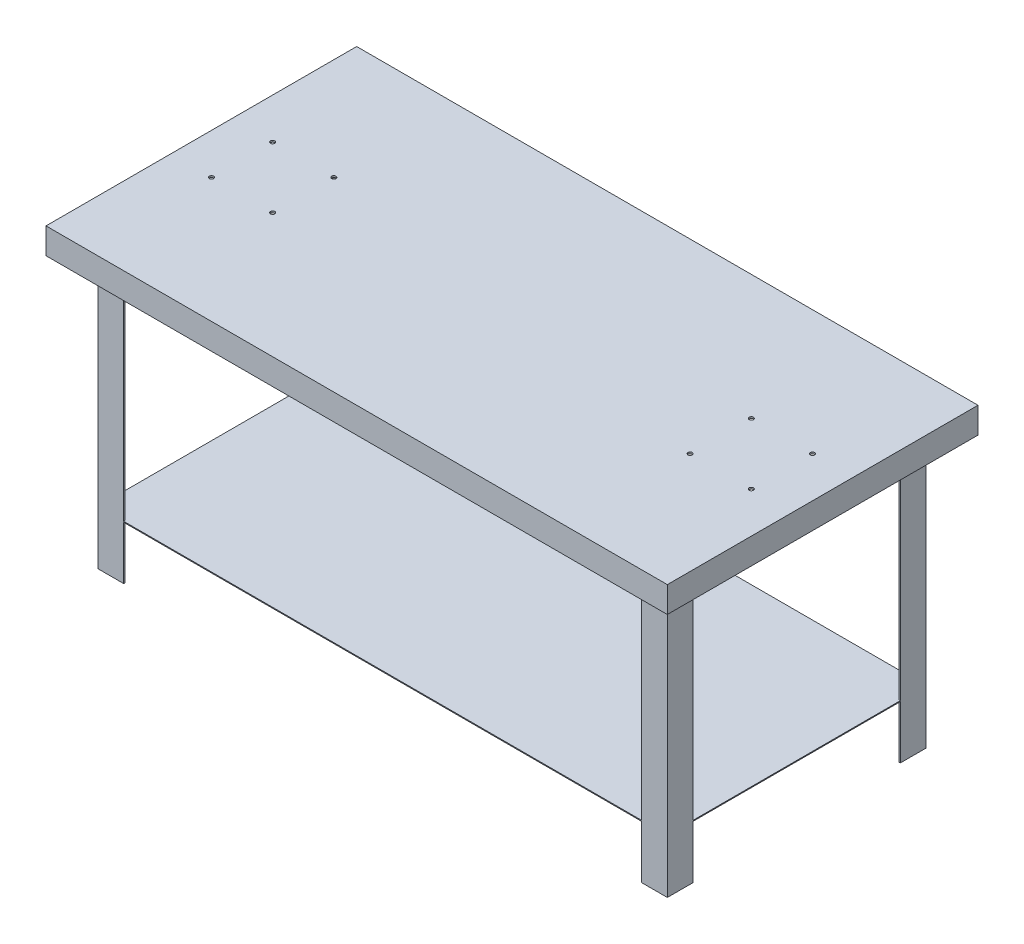
from build123d import *

# Parameters (mm, degrees)
BOSS_EXTRUDE1_DEPTH = 914.4
BOSS_EXTRUDE2_DEPTH = 457.2
BOSS_EXTRUDE3_DEPTH = 868.9975
BOSS_EXTRUDE4_START = 712.7875
SKETCH5_W           = 1676.4
SKETCH5_H           = 762
BOSS_EXTRUDE4_DEPTH = 2.657
SKETCH6_R           = 6.35
CUT_EXTRUDE1_DEPTH  = 10
BOSS_EXTRUDE5_DEPTH = 779


with BuildPart() as part:
    # Sketch1 → Boss-Extrude1 (new body, symmetric)
    with BuildSketch(Plane(origin=(0, 0, 0), x_dir=(0, 0, -1), z_dir=(1, 0, 0))):
        Polygon((-457.2, 0), (457.2, 0), (457.2, -76.2), (381, -76.2), (381, -71.4375), (452.4375, -71.4375), (452.4375, -4.7625), (-452.4375, -4.7625), (-452.4375, -71.4375), (-381, -71.4375), (-381, -76.2), (-457.2, -76.2), align=None)
    extrude(amount=BOSS_EXTRUDE1_DEPTH, both=True)

    # Sketch2 → Boss-Extrude2 (add, symmetric)
    with BuildSketch(Plane.XY):
        Polygon((-914.4, 0), (-914.4, -76.2), (-838.2, -76.2), (-838.2, -71.4375), (-909.6375, -71.4375), (-909.6375, 0), align=None)
        Polygon((909.6375, 0), (914.4, 0), (914.4, -76.2), (838.2, -76.2), (838.2, -71.4375), (909.6375, -71.4375), align=None)
    extrude(amount=BOSS_EXTRUDE2_DEPTH, both=True)

    # Sketch4 → Boss-Extrude3 (add)
    with BuildSketch(Plane.XZ.offset(4.7625)):
        Polygon((-762, 381), (-838.2, 381), (-838.2, 304.8), (-833.646, 304.8), (-833.646, 376.446), (-762, 376.446), align=None)
        Polygon((-833.646, -376.446), (-762, -376.446), (-762, -381), (-838.2, -381), (-838.2, -304.8), (-833.646, -304.8), align=None)
        Polygon((833.646, -304.8), (833.646, -376.446), (762, -376.446), (762, -381), (838.2, -381), (838.2, -304.8), align=None)
        Polygon((833.646, 376.446), (762, 376.446), (762, 381), (838.2, 381), (838.2, 304.8), (833.646, 304.8), align=None)
    extrude(amount=BOSS_EXTRUDE3_DEPTH)

    # Sketch5 → Boss-Extrude4 (add)
    with BuildSketch(Plane.XZ.offset(4.7625).offset(BOSS_EXTRUDE4_START)):
        Rectangle(SKETCH5_W, SKETCH5_H)
    extrude(amount=-BOSS_EXTRUDE4_DEPTH)

    # Sketch6 → Cut-Extrude1 (cut)
    with BuildSketch(Plane(origin=(0, 0, 0), x_dir=(1, 0, 0), z_dir=(0, 1, 0))):
        with Locations((-794.4, 90)):
            Circle(SKETCH6_R)
        with Locations((-614.4, 90)):
            Circle(SKETCH6_R)
        with Locations((-794.4, -90)):
            Circle(SKETCH6_R)
        with Locations((-614.4, -90)):
            Circle(SKETCH6_R)
        with Locations((614.4, -90)):
            Circle(SKETCH6_R)
        with Locations((794.4, -90)):
            Circle(SKETCH6_R)
        with Locations((794.4, 90)):
            Circle(SKETCH6_R)
        with Locations((614.4, 90)):
            Circle(SKETCH6_R)
    extrude(amount=-CUT_EXTRUDE1_DEPTH, mode=Mode.SUBTRACT)

    # Sketch7 → Boss-Extrude5 (add, symmetric)
    with BuildSketch(Plane(origin=(0, 0, 0), x_dir=(0, 0, -1), z_dir=(1, 0, 0))):
        Polygon((63.172612778, -4.7625), (50.8, -4.7625), (0, -66.038420526), (-50.8, -4.7625), (-63.172612778, -4.7625), (0, -80.9625), align=None)
    extrude(amount=BOSS_EXTRUDE5_DEPTH, both=True)


solid = part.part
